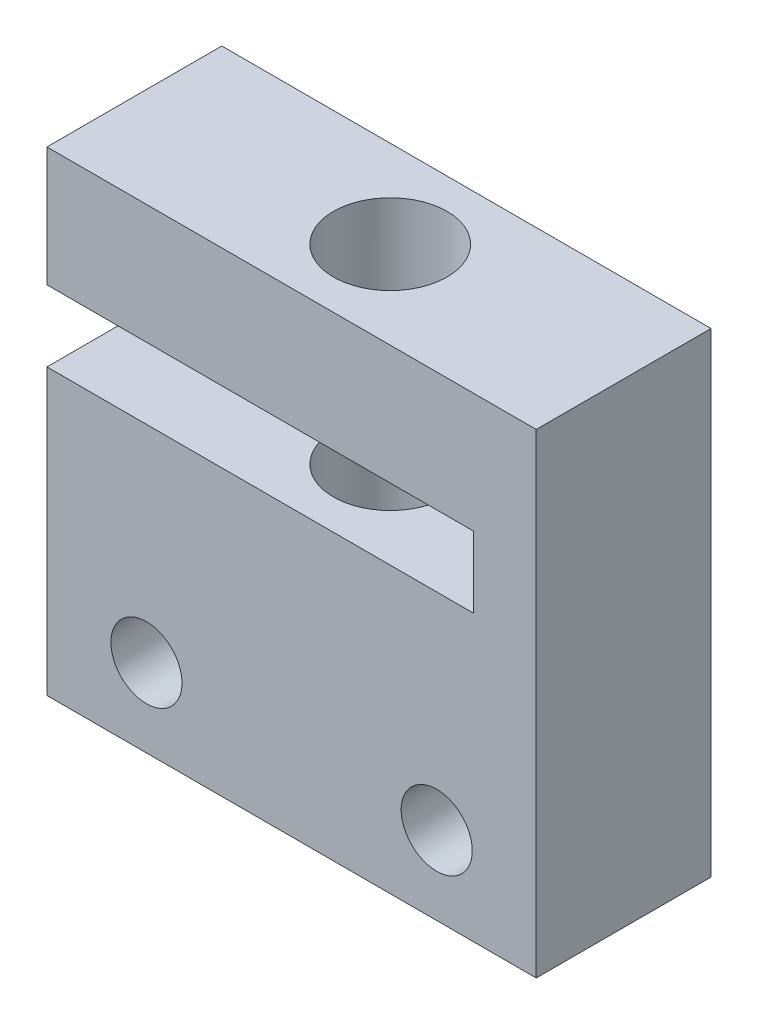
from build123d import *

# Parameters (mm, degrees)
SKETCH1_R           = 2.5
BOSS_EXTRUDE1_DEPTH = 12.3
SKETCH2_R           = 4
CUT_EXTRUDE1_DEPTH  = 34.42


with BuildPart() as part:
    # Sketch1 → Boss-Extrude1 (new body)
    with BuildSketch(Plane.XY):
        Polygon((0, 25.02), (30, 25.02), (30, 20.02), (0, 20.02), (0, 0), (34.42, 0), (34.42, 33.42), (0, 33.42), align=None)
        with Locations((27.42, 5.5)):
            Circle(SKETCH1_R, mode=Mode.SUBTRACT)
        with Locations((7, 5.5)):
            Circle(SKETCH1_R, mode=Mode.SUBTRACT)
    extrude(amount=BOSS_EXTRUDE1_DEPTH)

    # Sketch2 → Cut-Extrude1 (cut, through all)
    with BuildSketch(Plane(origin=(0, 0, 0), x_dir=(-1, 0, 0), z_dir=(0, -1, 0))):
        with Locations((-18, -6.15)):
            Circle(SKETCH2_R)
    extrude(amount=-CUT_EXTRUDE1_DEPTH, mode=Mode.SUBTRACT)


solid = part.part
